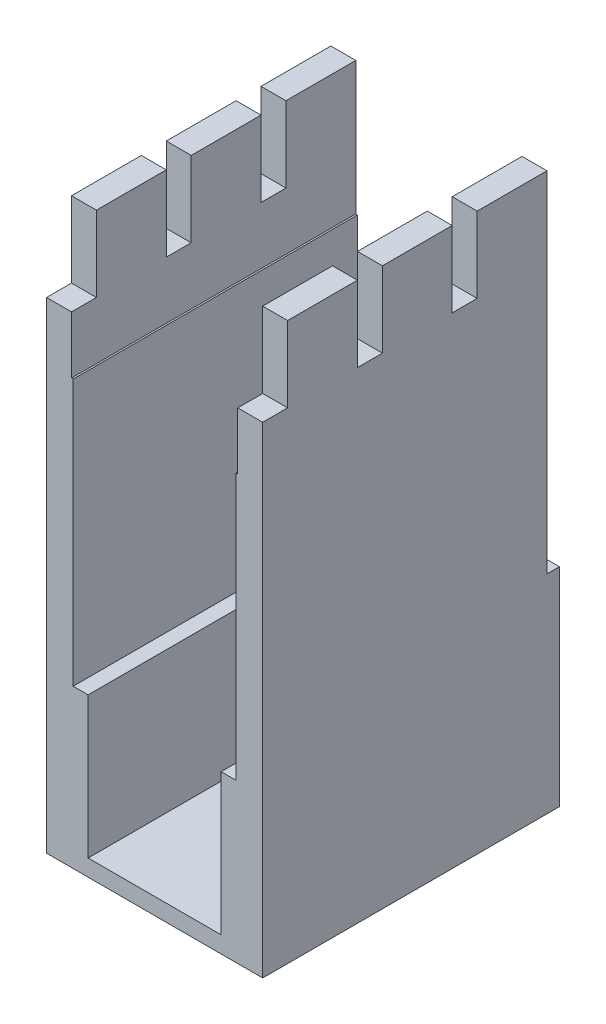
from build123d import *

# Parameters (mm, degrees)
BOSS_EXTRUDE1_DEPTH = 54
SKETCH2_W           = 3
SKETCH2_H           = 9.1
CUT_EXTRUDE1_DEPTH  = 27
SKETCH3_W           = 26
SKETCH3_H           = 25
BOSS_EXTRUDE2_DEPTH = 1.5


with BuildPart() as part:
    # Sketch1 → Boss-Extrude1 (new body)
    with BuildSketch(Plane.XY):
        Polygon((-13, 67), (-13, 0), (13, 0), (13, 67), (10, 67), (10, 51), (9.8, 51), (9.8, 19), (8, 19), (8, 2), (-8, 2), (-8, 19), (-9.8, 19), (-9.8, 51), (-10, 51), (-10, 67), align=None)
    extrude(amount=BOSS_EXTRUDE1_DEPTH)

    # Sketch2 → Cut-Extrude1 (cut, through all)
    with BuildSketch(Plane(origin=(13, 0, 0), x_dir=(0, 0, -1), z_dir=(1, 0, 0))):
        Polygon((-45.6, 57.9), (-45.6, 67), (-54, 67), (-54, 0), (-34.2, 0), (-34.2, 57.9), (-34.2, 67), (-42.6, 67), (-42.6, 57.9), align=None)
        with Locations((-32.7, 62.45)):
            Rectangle(SKETCH2_W, SKETCH2_H)
        with Locations((-21.3, 62.45)):
            Rectangle(SKETCH2_W, SKETCH2_H)
        with Locations((-9.9, 62.45)):
            Rectangle(SKETCH2_W, SKETCH2_H)
        with Locations((-44.1, 62.45)):
            Rectangle(SKETCH2_W, SKETCH2_H)
    extrude(amount=-CUT_EXTRUDE1_DEPTH, mode=Mode.SUBTRACT)

    # Sketch3 → Boss-Extrude2 (add)
    with BuildSketch(Plane(origin=(0, 0, 0), x_dir=(-1, 0, 0), z_dir=(0, 0, -1))):
        with Locations((0, 12.5)):
            Rectangle(SKETCH3_W, SKETCH3_H)
    extrude(amount=BOSS_EXTRUDE2_DEPTH)


solid = part.part
